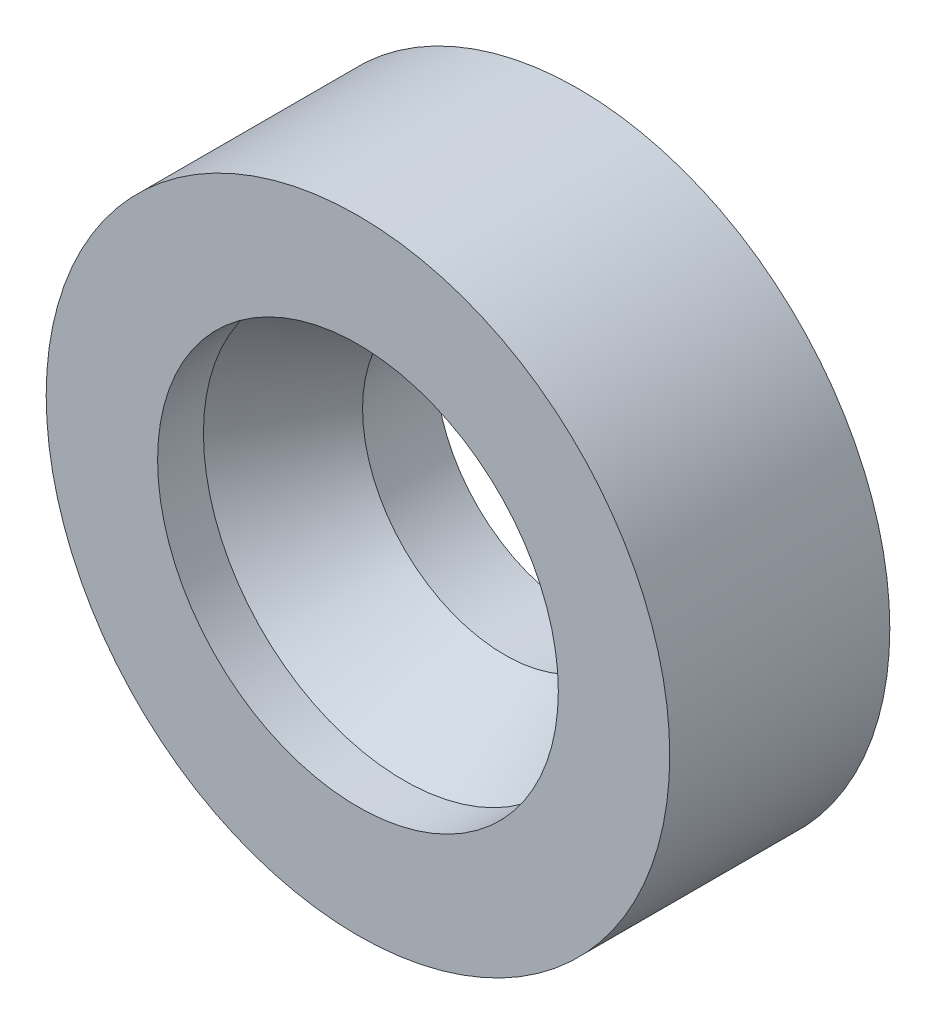
from build123d import *

# Parameters (mm, degrees)
SKETCH1_R           = 3.4
BOSS_EXTRUDE1_DEPTH = 2.4
SKETCH2_R           = 1.55
CUT_EXTRUDE1_DEPTH  = 0.8
SKETCH3_R           = 1.55
CUT_EXTRUDE2_DEPTH  = 1.1
CUT_EXTRUDE2_TAPER  = -30
CUT_EXTRUDE3_REACH  = 2.5
SKETCH4_R           = 2.185085296


with BuildPart() as part:
    # Sketch1 → Boss-Extrude1 (new body)
    with BuildSketch(Plane.XY):
        Circle(SKETCH1_R)
    extrude(amount=BOSS_EXTRUDE1_DEPTH)

    # Sketch2 → Cut-Extrude1 (cut)
    with BuildSketch(Plane(origin=(0, 0, 0), x_dir=(-1, 0, 0), z_dir=(0, 0, -1))):
        Circle(SKETCH2_R)
    extrude(amount=-CUT_EXTRUDE1_DEPTH, mode=Mode.SUBTRACT)

    # Sketch3 → Cut-Extrude2 (cut)
    with BuildSketch(Plane(origin=(0, 0, 0.8), x_dir=(-1, 0, 0), z_dir=(0, 0, -1))):
        Circle(SKETCH3_R)
    extrude(amount=-CUT_EXTRUDE2_DEPTH, taper=CUT_EXTRUDE2_TAPER, mode=Mode.SUBTRACT)

    # Sketch4 → Cut-Extrude3 (cut, up to next)
    with BuildSketch(Plane(origin=(0, 0, 1.9), x_dir=(-1, 0, 0), z_dir=(0, 0, -1)), mode=Mode.PRIVATE) as cut_extrude3_sk1:
        Circle(SKETCH4_R)
    cut_extrude3_tool1 = extrude(cut_extrude3_sk1.sketch, amount=-CUT_EXTRUDE3_REACH, mode=Mode.PRIVATE) & part.part
    add(cut_extrude3_tool1.solids().sort_by_distance((0, 0, 1.9))[0], mode=Mode.SUBTRACT)


solid = part.part
